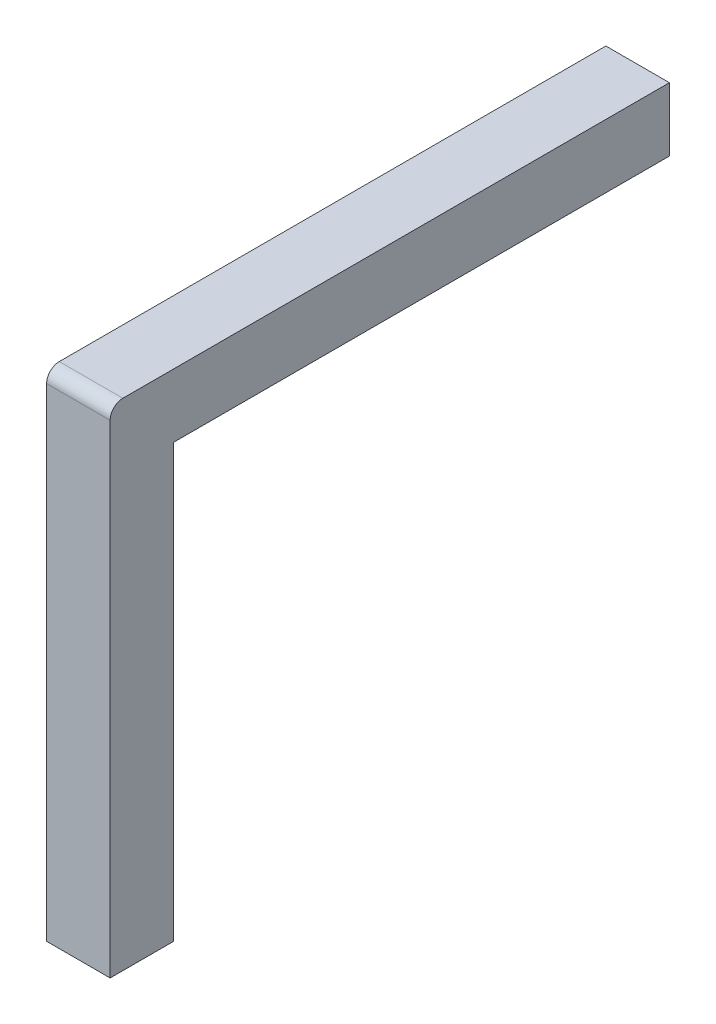
from build123d import *

# Parameters (mm, degrees)
SKETCH2_W           = 1
SKETCH2_H           = 1
BOSS_EXTRUDE1_DEPTH = 8
SKETCH3_W           = 1
SKETCH3_H           = 1
BOSS_EXTRUDE2_DEPTH = 8
FILLET1_R           = 0.2
CHAMFER1_SIZE       = 0.2
CHAMFER2_SIZE       = 0.2


with BuildPart() as part:
    # Sketch2 → Boss-Extrude1 (new body)
    with BuildSketch(Plane(origin=(0, 0, 0), x_dir=(1, 0, 0), z_dir=(0, 1, 0))):
        Rectangle(SKETCH2_W, SKETCH2_H)
    extrude(amount=BOSS_EXTRUDE1_DEPTH)

    # Sketch3 → Boss-Extrude2 (add)
    with BuildSketch(Plane(origin=(0, 0, -0.5), x_dir=(-1, 0, 0), z_dir=(0, 0, -1))):
        with Locations((0, 7.5)):
            Rectangle(SKETCH3_W, SKETCH3_H)
    extrude(amount=BOSS_EXTRUDE2_DEPTH)

    # Fillet1
    fillet1_edges = [part.edges().sort_by_distance(p)[0] for p in [
        (0, 8, 0.5),
    ]]
    fillet(fillet1_edges, radius=FILLET1_R)

    # Chamfer1
    chamfer1_edges = [part.edges().sort_by_distance(p)[0] for p in [
        (0.5, 7.5, -8.5),
        (0, 7, -8.5),
        (-0.5, 7.5, -8.5),
        (0, 8, -8.5),
    ]]
    chamfer(chamfer1_edges, length=CHAMFER1_SIZE)

    # Chamfer2
    chamfer2_edges = [part.edges().sort_by_distance(p)[0] for p in [
        (-0.5, 0, 0),
        (0, 0, -0.5),
        (0.5, 0, 0),
        (0, 0, 0.5),
    ]]
    chamfer(chamfer2_edges, length=CHAMFER2_SIZE)


solid = part.part
